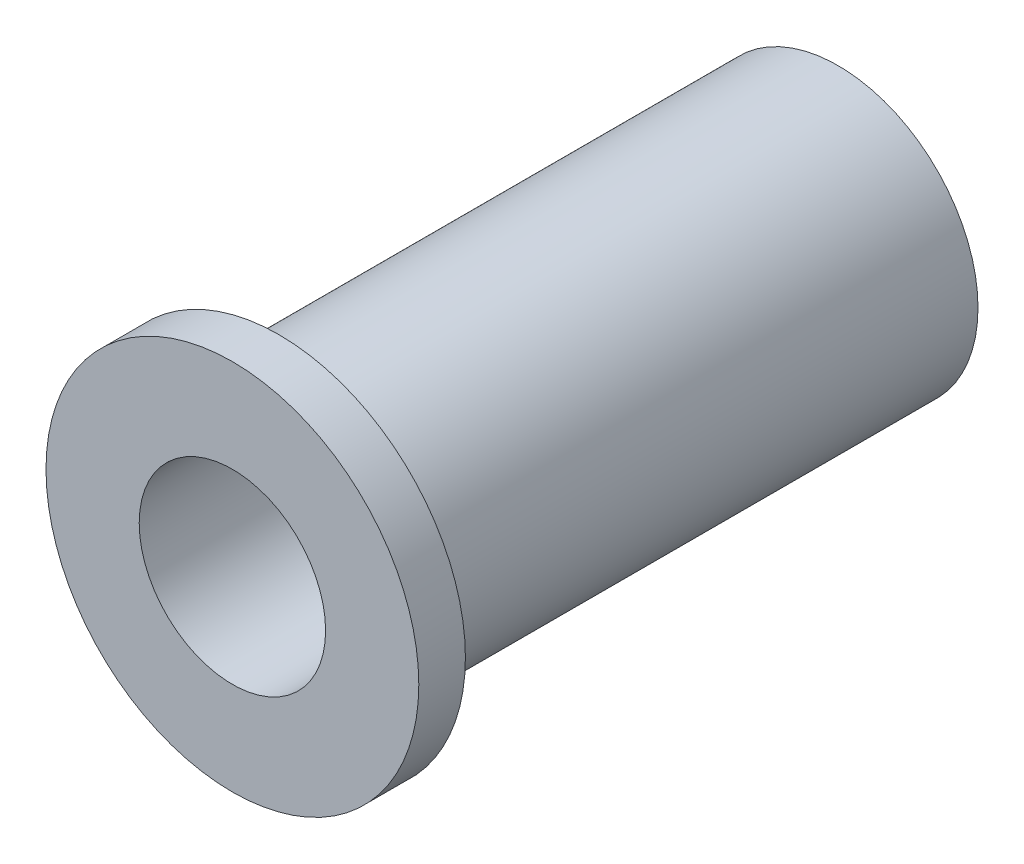
from build123d import *

# Parameters (mm, degrees)
SKETCH1_R           = 4.7625
SKETCH1_R_2         = 3.175
BOSS_EXTRUDE1_DEPTH = 19.05
SKETCH2_R           = 6.35
SKETCH2_R_2         = 3.175
BOSS_EXTRUDE2_DEPTH = 1.5875


with BuildPart() as part:
    # Sketch1 → Boss-Extrude1 (new body)
    with BuildSketch(Plane.XY):
        Circle(SKETCH1_R)
        Circle(SKETCH1_R_2, mode=Mode.SUBTRACT)
    extrude(amount=BOSS_EXTRUDE1_DEPTH)

    # Sketch2 → Boss-Extrude2 (add)
    with BuildSketch(Plane.XY.offset(19.05)):
        Circle(SKETCH2_R)
        Circle(SKETCH2_R_2, mode=Mode.SUBTRACT)
    extrude(amount=BOSS_EXTRUDE2_DEPTH)


solid = part.part
